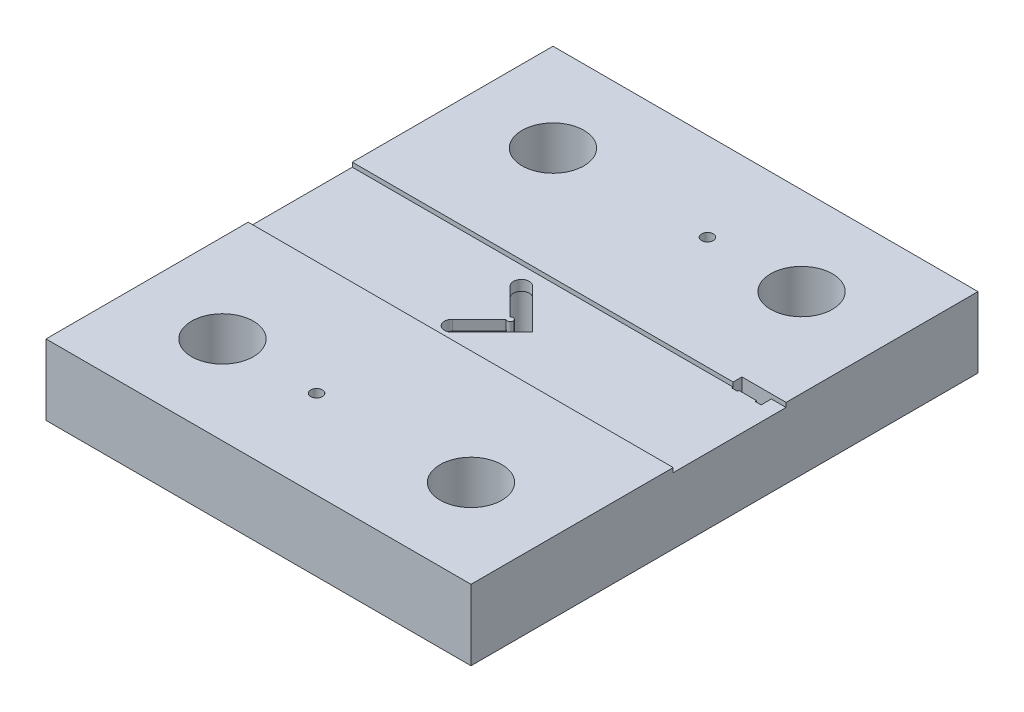
from build123d import *

# Parameters (mm, degrees)
SKETCH2_W           = 144.5
SKETCH2_H           = 172.38
BOSS_EXTRUDE1_DEPTH = 24
SKETCH3_R           = 10.5
SKETCH3_R_2         = 1.99
CUT_EXTRUDE2_DEPTH  = 25
CUT_EXTRUDE3_DEPTH  = 1.5
CUT_EXTRUDE4_DEPTH  = 19


with BuildPart() as part:
    # Sketch2 → Boss-Extrude1 (new body)
    with BuildSketch(Plane(origin=(0, 0, 0), x_dir=(1, 0, 0), z_dir=(0, 1, 0))):
        Rectangle(SKETCH2_W, SKETCH2_H)
    extrude(amount=BOSS_EXTRUDE1_DEPTH)

    # Sketch3 → Cut-Extrude2 (cut, through all)
    with BuildSketch(Plane(origin=(0, 24, 0), x_dir=(1, 0, 0), z_dir=(0, 1, 0))):
        with Locations((42.25, 56.19)):
            Circle(SKETCH3_R)
        with Locations((-42.25, 56.19)):
            Circle(SKETCH3_R)
        with Locations((-42.25, -56.19)):
            Circle(SKETCH3_R)
        with Locations((42.25, -56.19)):
            Circle(SKETCH3_R)
        with Locations((10.25, 56.19)):
            Circle(SKETCH3_R_2)
        with Locations((-10.25, -56.19)):
            Circle(SKETCH3_R_2)
        Polygon((57.25, 17.44), (59.25, 17.44), (59.25, 17.94), (65.25, 17.94), (65.25, 17.44), (67.25, 17.44), (67.25, 20.94), (57.25, 20.94), align=None)
        with BuildLine():
            Line((-10.455537495, 9.828784258), (-1.333860018, 0.707106781))
            ThreePointArc((-1.333860018, 0.707106781), (0.373246763, 0), (-1.333860018, -0.707106781))
            Line((-1.333860018, -0.707106781), (-10.455537495, -9.828784258))
            ThreePointArc((-10.455537495, -9.828784258), (-10.455537495, -13.647160877), (-6.637160877, -13.647160877))
            Line((-6.637160877, -13.647160877), (7.01, 0))
            Line((7.01, 0), (-6.637160877, 13.647160877))
            ThreePointArc((-6.637160877, 13.647160877), (-10.455537495, 13.647160877), (-10.455537495, 9.828784258))
        make_face()
    extrude(amount=-CUT_EXTRUDE2_DEPTH, mode=Mode.SUBTRACT)

    # Sketch5 → Cut-Extrude3 (cut)
    with BuildSketch(Plane(origin=(0, 24, 0), x_dir=(1, 0, 0), z_dir=(0, 1, 0))):
        Polygon((57.25, 17.94), (-72.25, 17.94), (-72.25, -17.44), (72.25, -17.44), (72.25, 20.94), (67.25, 20.94), (67.25, 17.44), (65.25, 17.44), (65.25, 17.94), (59.25, 17.94), (59.25, 17.44), (57.25, 17.44), align=None)
        with BuildLine():
            ThreePointArc((-1.333860018, -0.707106781), (0.373246763, 0), (-1.333860018, 0.707106781))
            Line((-1.333860018, 0.707106781), (-10.455537495, 9.828784258))
            ThreePointArc((-10.455537495, 9.828784258), (-10.455537495, 13.647160877), (-6.637160877, 13.647160877))
            Line((-6.637160877, 13.647160877), (7.01, 0))
            Line((7.01, 0), (-6.637160877, -13.647160877))
            ThreePointArc((-6.637160877, -13.647160877), (-10.455537495, -13.647160877), (-10.455537495, -9.828784258))
            Line((-10.455537495, -9.828784258), (-1.333860018, -0.707106781))
        make_face(mode=Mode.SUBTRACT)
    extrude(amount=-CUT_EXTRUDE3_DEPTH, mode=Mode.SUBTRACT)

    # Sketch7 → Cut-Extrude4 (cut)
    with BuildSketch(Plane.XZ):
        with BuildLine():
            Line((-2.040966799, 0), (-11.162644276, -9.121677477))
            ThreePointArc((-11.162644276, -9.121677477), (-11.162644276, -14.354267658), (-5.930054096, -14.354267658))
            Line((-5.930054096, -14.354267658), (8.424213562, 0))
            Line((8.424213562, 0), (-5.930054096, 14.354267658))
            ThreePointArc((-5.930054096, 14.354267658), (-11.162644276, 14.354267658), (-11.162644276, 9.121677477))
            Line((-11.162644276, 9.121677477), (-2.040966799, 0))
        make_face()
    extrude(amount=-CUT_EXTRUDE4_DEPTH, mode=Mode.SUBTRACT)


solid = part.part
